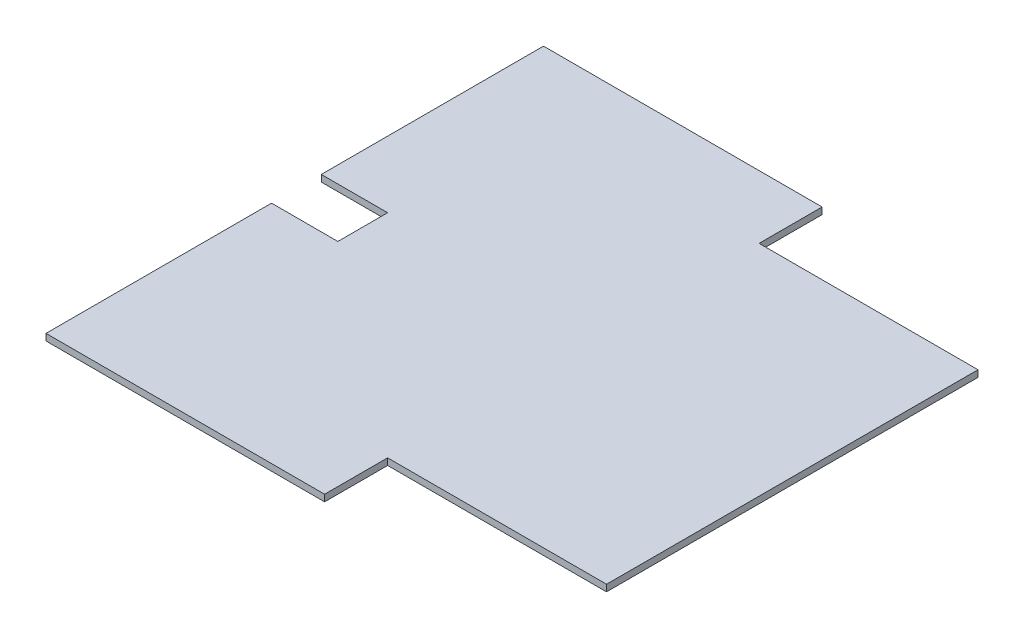
from build123d import *

# Parameters (mm, degrees)
SKETCH1_W           = 150
SKETCH1_H           = 150
BOSS_EXTRUDE1_DEPTH = 2
CUT_EXTRUDE2_REACH  = 4
SKETCH4_W           = 20
SKETCH4_H           = 15
CUT_EXTRUDE3_REACH  = 4
SKETCH7_W           = 66
SKETCH7_H           = 19


with BuildPart() as part:
    # Sketch1 → Boss-Extrude1 (new body)
    with BuildSketch(Plane(origin=(0, 0, 0), x_dir=(1, 0, 0), z_dir=(0, 1, 0))):
        Rectangle(SKETCH1_W, SKETCH1_H)
    extrude(amount=BOSS_EXTRUDE1_DEPTH)

    # Sketch4 → Cut-Extrude2 (cut, up to next)
    with BuildSketch(Plane(origin=(0, 2, 0), x_dir=(1, 0, 0), z_dir=(0, 1, 0)), mode=Mode.PRIVATE) as cut_extrude2_sk1:
        with Locations((-65, 0.5)):
            Rectangle(SKETCH4_W, SKETCH4_H)
    cut_extrude2_tool1 = extrude(cut_extrude2_sk1.sketch, amount=-CUT_EXTRUDE2_REACH, mode=Mode.PRIVATE) & part.part
    add(cut_extrude2_tool1.solids().sort_by_distance((-65, 2, -0.5))[0], mode=Mode.SUBTRACT)

    # Sketch7 → Cut-Extrude3 (cut, up to next)
    with BuildSketch(Plane.XZ, mode=Mode.PRIVATE) as cut_extrude3_sk1:
        with Locations((42, 65.5)):
            Rectangle(SKETCH7_W, SKETCH7_H)
    cut_extrude3_tool1 = extrude(cut_extrude3_sk1.sketch, amount=-CUT_EXTRUDE3_REACH, mode=Mode.PRIVATE) & part.part
    add(cut_extrude3_tool1.solids().sort_by_distance((42, 0, 65.5))[0], mode=Mode.SUBTRACT)
    # Sketch7 → Cut-Extrude3 (cut, up to next)
    with BuildSketch(Plane.XZ, mode=Mode.PRIVATE) as cut_extrude3_sk2:
        with Locations((42, -65.5)):
            Rectangle(SKETCH7_W, SKETCH7_H)
    cut_extrude3_tool2 = extrude(cut_extrude3_sk2.sketch, amount=-CUT_EXTRUDE3_REACH, mode=Mode.PRIVATE) & part.part
    add(cut_extrude3_tool2.solids().sort_by_distance((42, 0, -65.5))[0], mode=Mode.SUBTRACT)


solid = part.part
